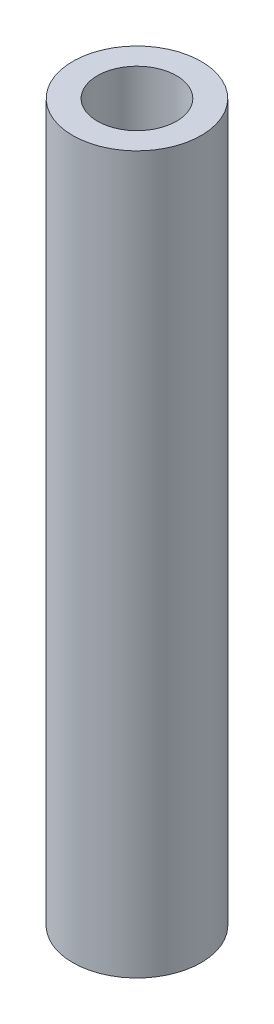
from build123d import *

# Parameters (mm, degrees)
SKETCH1_R           = 2.6
SKETCH1_R_2         = 1.6
BOSS_EXTRUDE1_DEPTH = 29


with BuildPart() as part:
    # Sketch1 → Boss-Extrude1 (new body)
    with BuildSketch(Plane(origin=(0, 0, 0), x_dir=(1, 0, 0), z_dir=(0, 1, 0))):
        Circle(SKETCH1_R)
        Circle(SKETCH1_R_2, mode=Mode.SUBTRACT)
    extrude(amount=BOSS_EXTRUDE1_DEPTH)


solid = part.part
